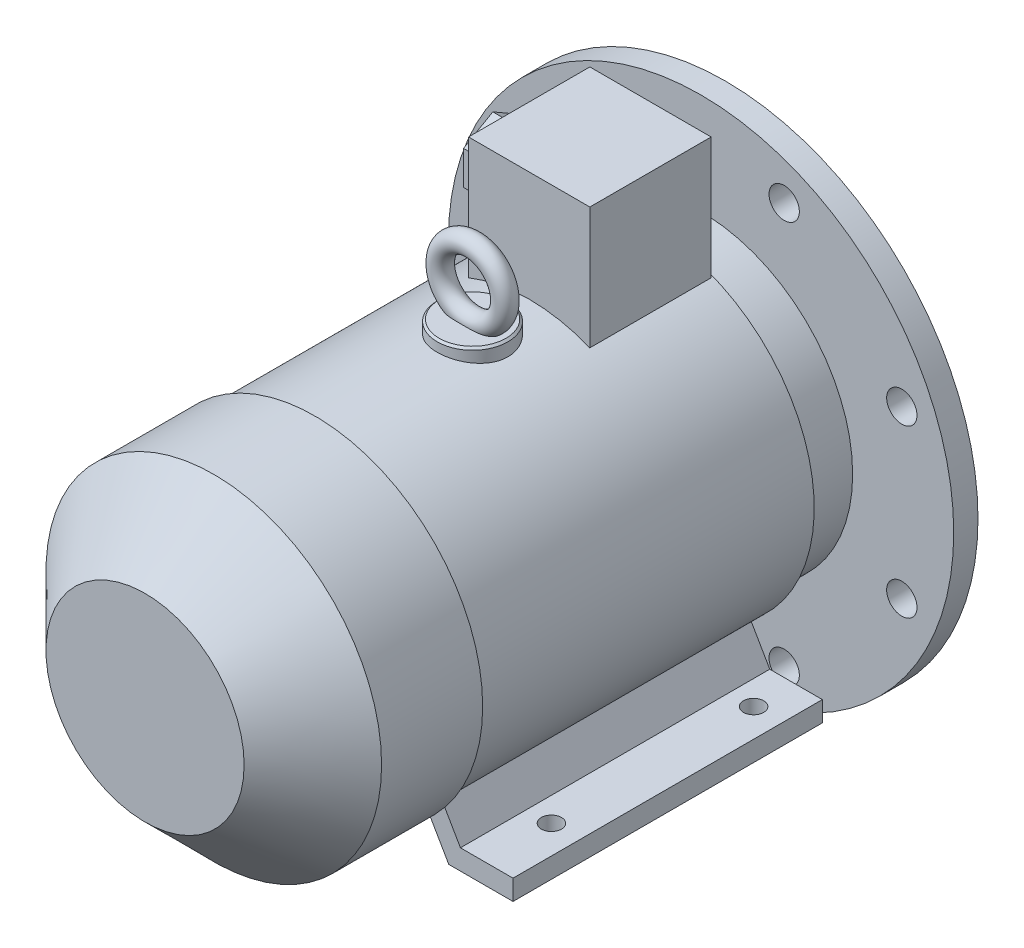
from build123d import *

# Parameters (mm, degrees)
SKETCH_1_R           = 12
EXTRUDE_1_DEPTH      = 50
SKETCH_2_W           = 7
SKETCH_2_H           = 7
EXTRUDE_2_DEPTH      = 0.1
EXTRUDE_2_DEPTH_BACK = 25
SKETCH_3_R           = 125
EXTRUDE_3_DEPTH      = 12
SKETCH_4_R           = 90
SKETCH_4_R_2         = 85
EXTRUDE_4_DEPTH      = 4
SKETCH_5_R           = 85
SKETCH_5_R_2         = 20
CUT_EXTRUDE_1_DEPTH  = 4
CHAMFER_1_SIZE       = 1
SKETCH_6_R           = 7.5
CUT_EXTRUDE_2_DEPTH  = 13
SKETCH_7_R           = 75
EXTRUDE_5_DEPTH      = 24
SKETCH_8_R           = 80
EXTRUDE_6_DEPTH      = 167
SKETCH_9_R           = 83
EXTRUDE_7_DEPTH      = 84
CHAMFER_2_SIZE       = 34
EXTRUDE_8_DEPTH      = 153
CUT_EXTRUDE_3_REACH  = 217
SKETCH_11_R          = 5
SKETCH_12_W          = 60
SKETCH_12_H          = 60
EXTRUDE_9_DEPTH      = 134.5
SKETCH_13_R          = 17.5
EXTRUDE_10_DEPTH     = 85.5
CHAMFER_3_SIZE       = 1
SKETCH_15_R          = 5
SKETCH_16_R          = 9
EXTRUDE_11_DEPTH     = 8
EXTRUDE_12_DEPTH     = 10
SKETCH_18_R          = 6
CUT_EXTRUDE_4_DEPTH  = 10


with BuildPart() as part:
    # Эскиз1 → Вытянуть1 (new body)
    with BuildSketch(Plane.XY):
        Circle(SKETCH_1_R)
    extrude(amount=EXTRUDE_1_DEPTH)

    # Эскиз2 → Вытянуть2 (add, two sides)
    with BuildSketch(Plane(origin=(0, 0, 0), x_dir=(-1, 0, 0), z_dir=(0, 0, -1))) as extrude_2_sk:
        with Locations((0, 11.5)):
            Rectangle(SKETCH_2_W, SKETCH_2_H)
    extrude(amount=EXTRUDE_2_DEPTH)
    extrude(extrude_2_sk.sketch, amount=-EXTRUDE_2_DEPTH_BACK)

    # Эскиз3 → Вытянуть3 (add)
    with BuildSketch(Plane.XY.offset(50)):
        Circle(SKETCH_3_R)
    extrude(amount=EXTRUDE_3_DEPTH)

    # Эскиз4 → Вытянуть4 (add)
    with BuildSketch(Plane(origin=(0, 0, 50), x_dir=(-1, 0, 0), z_dir=(0, 0, -1))):
        with Locations(Location((0, 0, 0), (0, 0, 180))):  # turned: the seam where the file's is
            Circle(SKETCH_4_R)
        Circle(SKETCH_4_R_2, mode=Mode.SUBTRACT)
    extrude(amount=EXTRUDE_4_DEPTH)

    # Эскиз5 → Вырез-Вытянуть1 (cut)
    with BuildSketch(Plane(origin=(0, 0, 50), x_dir=(-1, 0, 0), z_dir=(0, 0, -1))):
        Circle(SKETCH_5_R)
        Circle(SKETCH_5_R_2, mode=Mode.SUBTRACT)
    extrude(amount=-CUT_EXTRUDE_1_DEPTH, mode=Mode.SUBTRACT)

    # Фаска1
    chamfer_1_edges = [part.edges().sort_by_distance(p)[0] for p in [
        (-90, 0, 46),
        (20, 0, 50),
        (-7.141428429, -9.643650761, 0),
    ]]
    chamfer(chamfer_1_edges, length=CHAMFER_1_SIZE)

    # Эскиз6 → Вырез-Вытянуть2 (cut, through all)
    with BuildSketch(Plane(origin=(0, 0, 50), x_dir=(-1, 0, 0), z_dir=(0, 0, -1))):
        with Locations((-41.138468979, 99.317049745)):
            Circle(SKETCH_6_R)
        with Locations((41.138468979, 99.317049745)):
            Circle(SKETCH_6_R)
        with Locations((99.317049745, 41.138468979)):
            Circle(SKETCH_6_R)
        with Locations((99.317049745, -41.138468979)):
            Circle(SKETCH_6_R)
        with Locations((41.138468979, -99.317049745)):
            Circle(SKETCH_6_R)
        with Locations((-41.138468979, -99.317049745)):
            Circle(SKETCH_6_R)
        with Locations((-99.317049745, -41.138468979)):
            Circle(SKETCH_6_R)
        with Locations((-99.317049745, 41.138468979)):
            Circle(SKETCH_6_R)
    extrude(amount=-CUT_EXTRUDE_2_DEPTH, mode=Mode.SUBTRACT)

    # Эскиз7 → Вытянуть5 (add)
    with BuildSketch(Plane.XY.offset(62)):
        Circle(SKETCH_7_R)
    extrude(amount=EXTRUDE_5_DEPTH)

    # Эскиз8 → Вытянуть6 (add)
    with BuildSketch(Plane.XY.offset(86)):
        Circle(SKETCH_8_R)
    extrude(amount=EXTRUDE_6_DEPTH)

    # Эскиз9 → Вытянуть7 (add)
    with BuildSketch(Plane.XY.offset(253)):
        Circle(SKETCH_9_R)
    extrude(amount=EXTRUDE_7_DEPTH)

    # Фаска2
    chamfer_2_edges = [part.edges().sort_by_distance(p)[0] for p in [
        (-83, 0, 337),
    ]]
    chamfer(chamfer_2_edges, length=CHAMFER_2_SIZE)

    # Эскиз10 → Вытянуть8 (add)
    with BuildSketch(Plane(origin=(0, 0, 86), x_dir=(-1, 0, 0), z_dir=(0, 0, -1))):
        Polygon((-84, -90), (-52.226497308, -90), (-38.625494231, -66.442371637), (-46.977009654, -60.90762067), (-58, -80), (-84, -80), align=None)
        Polygon((84, -90), (84, -80), (58, -80), (46.977009654, -60.90762067), (38.625494231, -66.442371637), (52.226497308, -90), align=None)
    extrude(amount=-EXTRUDE_8_DEPTH)

    # Эскиз11 → Вырез-Вытянуть3 (cut, up to next)
    with BuildSketch(Plane.XZ.offset(90), mode=Mode.PRIVATE) as cut_extrude_3_sk1:
        with Locations(Location((-70, 106, 0), (0, 0, 270))):  # turned: the seam where the file's is
            Circle(SKETCH_11_R)
    cut_extrude_3_tool1 = extrude(cut_extrude_3_sk1.sketch, amount=-CUT_EXTRUDE_3_REACH, mode=Mode.PRIVATE) & part.part
    add(cut_extrude_3_tool1.solids().sort_by_distance((-70, -90, 106))[0], mode=Mode.SUBTRACT)
    # Эскиз11 → Вырез-Вытянуть3 (cut, up to next)
    with BuildSketch(Plane.XZ.offset(90), mode=Mode.PRIVATE) as cut_extrude_3_sk2:
        with Locations(Location((70, 106, 0), (0, 0, 270))):  # turned: the seam where the file's is
            Circle(SKETCH_11_R)
    cut_extrude_3_tool2 = extrude(cut_extrude_3_sk2.sketch, amount=-CUT_EXTRUDE_3_REACH, mode=Mode.PRIVATE) & part.part
    add(cut_extrude_3_tool2.solids().sort_by_distance((70, -90, 106))[0], mode=Mode.SUBTRACT)
    # Эскиз11 → Вырез-Вытянуть3 (cut, up to next)
    with BuildSketch(Plane.XZ.offset(90), mode=Mode.PRIVATE) as cut_extrude_3_sk3:
        with Locations(Location((-70, 206, 0), (0, 0, 270))):  # turned: the seam where the file's is
            Circle(SKETCH_11_R)
    cut_extrude_3_tool3 = extrude(cut_extrude_3_sk3.sketch, amount=-CUT_EXTRUDE_3_REACH, mode=Mode.PRIVATE) & part.part
    add(cut_extrude_3_tool3.solids().sort_by_distance((-70, -90, 206))[0], mode=Mode.SUBTRACT)
    # Эскиз11 → Вырез-Вытянуть3 (cut, up to next)
    with BuildSketch(Plane.XZ.offset(90), mode=Mode.PRIVATE) as cut_extrude_3_sk4:
        with Locations(Location((70, 206, 0), (0, 0, 270))):  # turned: the seam where the file's is
            Circle(SKETCH_11_R)
    cut_extrude_3_tool4 = extrude(cut_extrude_3_sk4.sketch, amount=-CUT_EXTRUDE_3_REACH, mode=Mode.PRIVATE) & part.part
    add(cut_extrude_3_tool4.solids().sort_by_distance((70, -90, 206))[0], mode=Mode.SUBTRACT)

    # Эскиз12 → Вытянуть9 (add)
    with BuildSketch(Plane(origin=(0, 0, 0), x_dir=(1, 0, 0), z_dir=(0, 1, 0))):
        with Locations((0, -117)):
            Rectangle(SKETCH_12_W, SKETCH_12_H)
    extrude(amount=EXTRUDE_9_DEPTH)

    # Эскиз13 → Вытянуть10 (add)
    with BuildSketch(Plane(origin=(0, 0, 0), x_dir=(1, 0, 0), z_dir=(0, 1, 0))):
        with Locations(Location((0, -175, 0), (0, 0, 90))):  # turned: the seam where the file's is
            Circle(SKETCH_13_R)
    extrude(amount=EXTRUDE_10_DEPTH)

    # Фаска3
    chamfer_3_edges = [part.edges().sort_by_distance(p)[0] for p in [
        (0, 85.5, 192.5),
    ]]
    chamfer(chamfer_3_edges, length=CHAMFER_3_SIZE)

    # По траектории1: sweep along a path in Эскиз14
    with BuildLine(Plane.XY.offset(175)) as sweep_1_path:
        CenterArc((0, 101.5), 16, 0, 360)
    # Эскиз15 → По траектории1 (sweep)
    with BuildSketch(Plane(origin=(0, 0, 0), x_dir=(0, 0, -1), z_dir=(1, 0, 0))):
        with Locations((-175, 117.5)):
            Circle(SKETCH_15_R)
    sweep(path=sweep_1_path.line)

    # Эскиз16 → Вытянуть11 (add)
    with BuildSketch(Plane.ZY.offset(30)):
        with Locations(Location((117, 104.5, 0), (0, 0, 180))):  # turned: the seam where the file's is
            Circle(SKETCH_16_R)
    extrude(amount=EXTRUDE_11_DEPTH)

    # Эскиз17 → Вытянуть12 (add)
    with BuildSketch(Plane.ZY.offset(38)):
        Polygon((117, 121.243157806), (102.5, 112.871578903), (102.5, 96.128421097), (117, 87.756842194), (131.5, 96.128421097), (131.5, 112.871578903), align=None)
    extrude(amount=EXTRUDE_12_DEPTH)

    # Эскиз18 → Вырез-Вытянуть4 (cut)
    with BuildSketch(Plane.ZY.offset(48)):
        with Locations((117, 104.5)):
            Circle(SKETCH_18_R)
    extrude(amount=-CUT_EXTRUDE_4_DEPTH, mode=Mode.SUBTRACT)


solid = part.part
